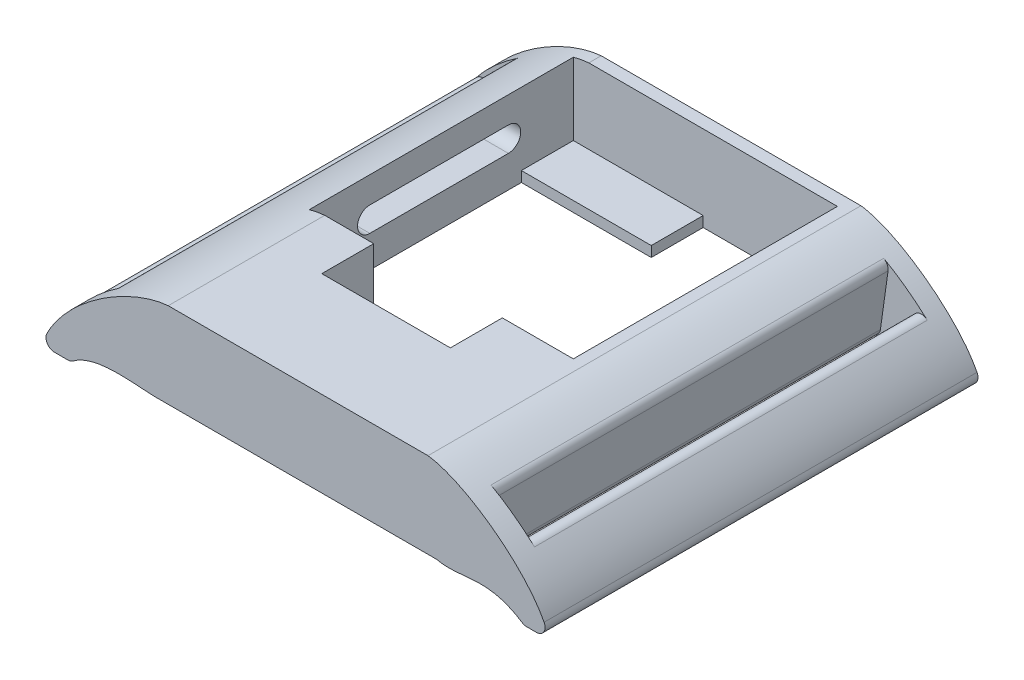
from build123d import *

# Parameters (mm, degrees)
BOSS_EXTRUDE1_DEPTH     = 50
FILLET1_R               = 1
CUT_EXTRUDE1_DEPTH      = 0.1
CUT_EXTRUDE1_DEPTH_BACK = 10
SKETCH4_W               = 3.286245436
SKETCH4_H               = 45.354465185
CUT_EXTRUDE3_DEPTH      = 59.6
FILLET2_R               = 1
SKETCH5_W               = 3.022487941
SKETCH5_H               = 46
CUT_EXTRUDE4_DEPTH      = 59.6
FILLET3_R               = 1
CUT_EXTRUDE6_DEPTH      = 10
SKETCH9_W               = 10
SKETCH9_H               = 1.2
BOSS_EXTRUDE3_DEPTH     = 8
FILLET4_R               = 1
SKETCH12_W              = 6
SKETCH12_H              = 1.2
BOSS_EXTRUDE5_DEPTH     = 15


with BuildPart() as part:
    # Sketch1 → Boss-Extrude1 (new body)
    with BuildSketch(Plane.XY):
        with BuildLine():
            Line((-16, -5.094562598), (16, -5.094562598))
            add(Edge.make_bspline(
                [(16, -5.094562598), (19.010163444, -5.778398589), (21.833873962, -3.708260231), (26.101632111, -6.636619387)],
                knots=[0, 0, 0, 0, 1, 1, 1, 1], degree=3))
            Line((26.101632111, -6.636619387), (28.993966503, -6.636619387))
            add(Edge.make_bspline(
                [(15, 4.776152435), (19.526584214, 4.22035778), (27.615247869, -1.736034796), (28.993966503, -6.636619387)],
                knots=[0, 0, 0, 0, 1, 1, 1, 1], degree=3))
            Line((15, 4.776152435), (-15, 4.776152435))
            add(Edge.make_bspline(
                [(-15, 4.776152435), (-19.817412976, 4.372269415), (-27.835022135, -0.825304327), (-29.60509257, -6.451000669)],
                knots=[0, 0, 0, 0, 1, 1, 1, 1], degree=3))
            Line((-29.60509257, -6.451000669), (-26.248659987, -6.451000669))
            add(Edge.make_bspline(
                [(-16, -5.094562598), (-18.471658339, -5.171044206), (-23.392499166, -4.043525333), (-26.248659987, -6.451000669)],
                knots=[0, 0, 0, 0, 1, 1, 1, 1], degree=3))
        make_face()
    extrude(amount=BOSS_EXTRUDE1_DEPTH)

    # Fillet1
    fillet1_edges = [part.edges().sort_by_distance(p)[0] for p in [
        (26.101632111, -6.636619387, 25),
        (-26.248659987, -6.451000669, 25),
    ]]
    fillet(fillet1_edges, radius=FILLET1_R)

    # Sketch2 → Cut-Extrude1 (cut, two sides)
    with BuildSketch(Plane.XZ.offset(5.094562598)) as cut_extrude1_sk:
        Polygon((-16.79152065, 31.925178446), (-9.34152065, 31.925178446), (-9.34152065, 37.925178446), (5.50847935, 37.925178446), (5.50847935, 31.925178446), (13.70847935, 31.925178446), (13.70847935, 1.425178446), (-16.79152065, 1.425178446), align=None)
    extrude(amount=CUT_EXTRUDE1_DEPTH, mode=Mode.SUBTRACT)
    extrude(cut_extrude1_sk.sketch, amount=-CUT_EXTRUDE1_DEPTH_BACK, mode=Mode.SUBTRACT)

    # Sketch4 → Cut-Extrude3 (cut)
    with BuildSketch(Plane(origin=(-0.391953903, -2.799772299, 0), x_dir=(-0.990342437, 0.138642912, 0), z_dir=(-0.138642912, -0.990342437, 0))):
        with Locations((-21.452352638, -24.822317059)):
            Rectangle(SKETCH4_W, SKETCH4_H)
    extrude(amount=-CUT_EXTRUDE3_DEPTH, mode=Mode.SUBTRACT)

    # Fillet2
    fillet2_edges = [part.edges().sort_by_distance(p)[0] for p in [
        (22.601064887, -5.140411885, 24.822317059),
        (19.285474309, -5.121114958, 24.822317059),
        (20.371507534, 2.636546632, 24.822317059),
        (23.394420174, 0.526617167, 24.822317059),
    ]]
    fillet(fillet2_edges, radius=FILLET2_R)

    # Sketch5 → Cut-Extrude4 (cut)
    with BuildSketch(Plane(origin=(0.37054441, -3.197379978, 0), x_dir=(-0.993351646, -0.115119536, 0), z_dir=(0.115119536, -0.993351646, 0))):
        with Locations((24.485742498, -24.88589819)):
            Rectangle(SKETCH5_W, SKETCH5_H)
    extrude(amount=-CUT_EXTRUDE4_DEPTH, mode=Mode.SUBTRACT)

    # Fillet3
    fillet3_edges = [part.edges().sort_by_distance(p)[0] for p in [
        (-22.548661147, -5.001313274, 24.88589819),
        (-26.046478247, -1.074313152, 24.88589819),
        (-23.272549949, 1.245029944, 24.88589819),
    ]]
    fillet(fillet3_edges, radius=FILLET3_R)

    # Sketch8 → Cut-Extrude6 (cut)
    with BuildSketch(Plane(origin=(-16.79152065, 0, 0), x_dir=(0, 0, -1), z_dir=(1, 0, 0))):
        with BuildLine():
            Line((-24.925178446, 1.419959303), (-8.925178446, 1.419959303))
            ThreePointArc((-8.925178446, 1.419959303), (-7.505219143, 0), (-8.925178446, -1.419959303))
            Line((-8.925178446, -1.419959303), (-24.925178446, -1.419959303))
            ThreePointArc((-24.925178446, -1.419959303), (-26.345137749, 0), (-24.925178446, 1.419959303))
        make_face()
    extrude(amount=-CUT_EXTRUDE6_DEPTH, mode=Mode.SUBTRACT)

    # Sketch9 → Boss-Extrude3 (add)
    with BuildSketch(Plane.ZY.offset(-13.70847935)):
        with Locations((26.925178446, -4.494562598)):
            Rectangle(SKETCH9_W, SKETCH9_H)
    extrude(amount=BOSS_EXTRUDE3_DEPTH)

    # Fillet4
    fillet4_edges = [part.edges().sort_by_distance(p)[0] for p in [
        (28.993966503, -6.636619387, 25),
        (-29.60509257, -6.451000669, 25),
    ]]
    fillet(fillet4_edges, radius=FILLET4_R)

    # Sketch12 → Boss-Extrude5 (add)
    with BuildSketch(Plane(origin=(-16.79152065, 0, 0), x_dir=(0, 0, -1), z_dir=(1, 0, 0))):
        with Locations((-4.425178446, -4.48687617)):
            Rectangle(SKETCH12_W, SKETCH12_H)
    extrude(amount=BOSS_EXTRUDE5_DEPTH)


solid = part.part
